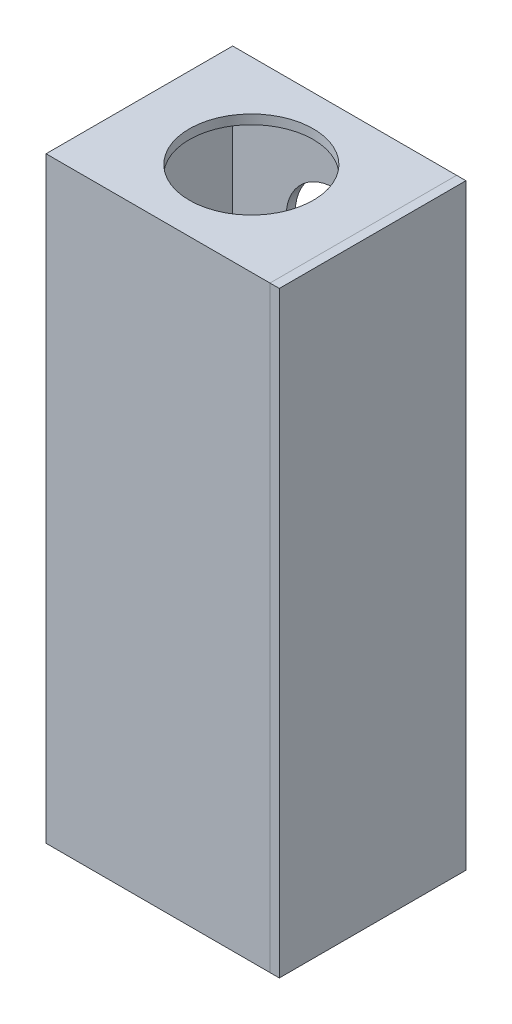
from build123d import *

# Parameters (mm, degrees)
SKETCH1_W           = 76.2
SKETCH1_H           = 63.5
BOSS_EXTRUDE1_DEPTH = 203.2
SHELL1_T            = -3.175
CUT_EXTRUDE1_REACH  = 205.2
SKETCH2_R           = 21.082
CUT_EXTRUDE2_REACH  = 65.5
SKETCH3_R           = 16.764
CUT_EXTRUDE3_REACH  = 78.2
SKETCH4_R           = 16.764
SKETCH5_W           = 63.5
SKETCH5_H           = 203.2
BOSS_EXTRUDE2_DEPTH = 3.175


with BuildPart() as part:
    # Sketch1 → Boss-Extrude1 (new body)
    with BuildSketch(Plane(origin=(0, 0, 0), x_dir=(1, 0, 0), z_dir=(0, 1, 0))):
        with Locations((38.1, 31.75)):
            Rectangle(SKETCH1_W, SKETCH1_H)
    extrude(amount=BOSS_EXTRUDE1_DEPTH)

    # Shell1
    shell1_openings = [part.faces().sort_by_distance(p)[0] for p in [
        (76.2, 101.6, -31.75),
    ]]
    offset(amount=SHELL1_T, openings=shell1_openings, kind=Kind.INTERSECTION)

    # Sketch2 → Cut-Extrude1 (cut, up to next)
    with BuildSketch(Plane(origin=(0, 203.2, 0), x_dir=(1, 0, 0), z_dir=(0, 1, 0)), mode=Mode.PRIVATE) as cut_extrude1_sk1:
        with Locations((38.1, 31.75)):
            Circle(SKETCH2_R)
    cut_extrude1_tool1 = extrude(cut_extrude1_sk1.sketch, amount=-CUT_EXTRUDE1_REACH, mode=Mode.PRIVATE) & part.part
    add(cut_extrude1_tool1.solids().sort_by_distance((38.1, 203.2, -31.75))[0], mode=Mode.SUBTRACT)

    # Sketch3 → Cut-Extrude2 (cut, up to next)
    with BuildSketch(Plane(origin=(0, 0, -63.5), x_dir=(-1, 0, 0), z_dir=(0, 0, -1)), mode=Mode.PRIVATE) as cut_extrude2_sk1:
        with Locations((-38.1, 165.1)):
            Circle(SKETCH3_R)
    cut_extrude2_tool1 = extrude(cut_extrude2_sk1.sketch, amount=-CUT_EXTRUDE2_REACH, mode=Mode.PRIVATE) & part.part
    add(cut_extrude2_tool1.solids().sort_by_distance((38.1, 165.1, -63.5))[0], mode=Mode.SUBTRACT)

    # Sketch4 → Cut-Extrude3 (cut, up to next)
    with BuildSketch(Plane.ZY, mode=Mode.PRIVATE) as cut_extrude3_sk1:
        with Locations((-31.75, 31.75)):
            Circle(SKETCH4_R)
    cut_extrude3_tool1 = extrude(cut_extrude3_sk1.sketch, amount=-CUT_EXTRUDE3_REACH, mode=Mode.PRIVATE) & part.part
    add(cut_extrude3_tool1.solids().sort_by_distance((0, 31.75, -31.75))[0], mode=Mode.SUBTRACT)


with BuildPart() as body_2:
    # Sketch5 → Boss-Extrude2 (new body)
    with BuildSketch(Plane(origin=(76.2, 0, 0), x_dir=(0, 0, -1), z_dir=(1, 0, 0))):
        with Locations((31.75, 101.6)):
            Rectangle(SKETCH5_W, SKETCH5_H)
    extrude(amount=BOSS_EXTRUDE2_DEPTH)


solid = Compound([part.part, body_2.part])
